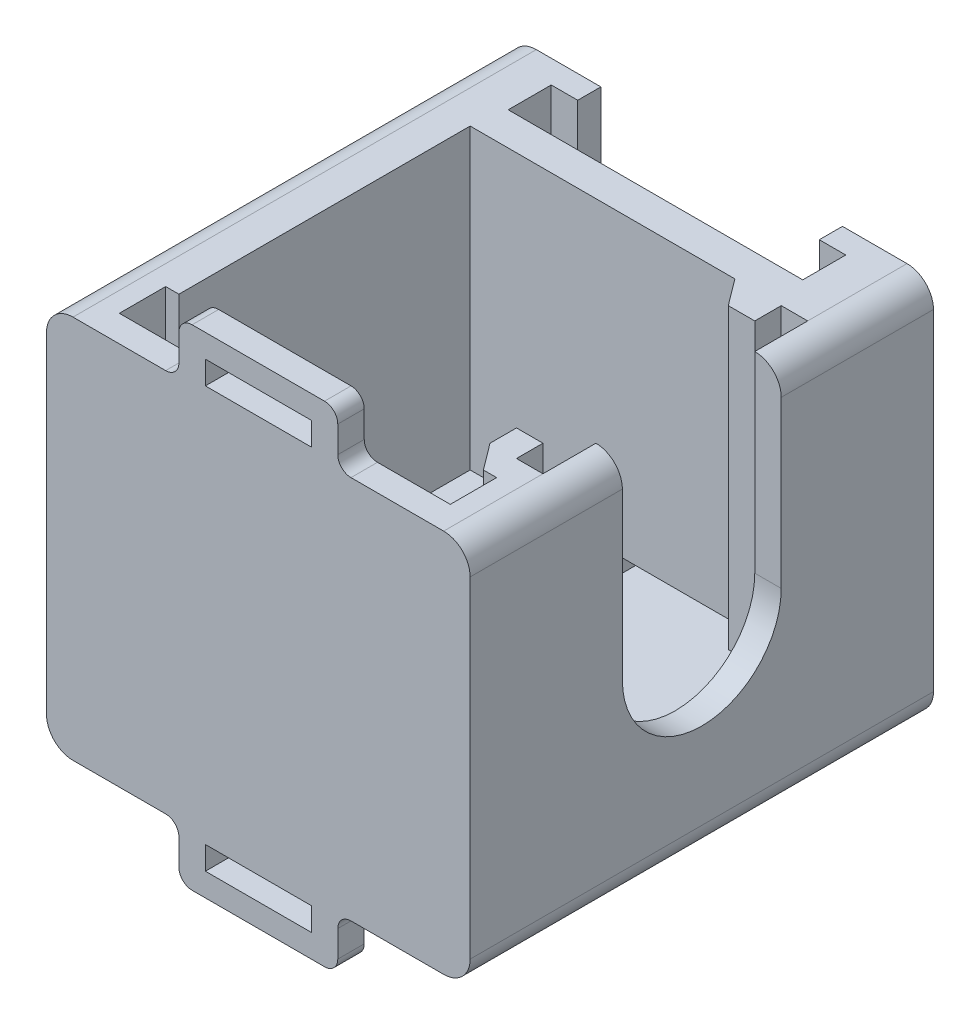
from build123d import *

# Parameters (mm, degrees)
SKETCH1_W                         = 32
SKETCH1_H                         = 29
BOSS_EXTRUDE1_DEPTH               = 35
FILLET1_R                         = 2
SLOT_FOR_COIL_DEPTH               = 1
SLOT_FOR_COIL_DEPTH_BACK          = 30
BOSS_EXTRUDE2_DEPTH               = 6.5
BOSS_EXTRUDE3_DEPTH               = 1.75
SKETCH5_W                         = 2
SKETCH5_H                         = 6.5
SLOT_TO_FEED_IN_WIRE_DEPTH        = 33
SLOT_FO_PCB_DEPTH                 = 22.5
SKETCH7_W                         = 2
SKETCH7_H                         = 33
BOSS_EXTRUDE4_DEPTH               = 2.5
FILLET2_R                         = 6
ROD_MOUNT_SLOT_REACH              = 34
SKETCH14_W                        = 2.5
SKETCH14_H                        = 20
SIDE_CAVITY_FOR_MOUNT_PLATE_DEPTH = 22.5
SKETCH16_W                        = 2
SKETCH16_H                        = 2
SIDE_STOPS_FOR_MOUNT_PLATE_DEPTH  = 22.5
BOSS_EXTRUDE6_DEPTH               = 22.5
SKETCH21_W                        = 12
SKETCH21_H                        = 2
BOSS_EXTRUDE7_DEPTH               = 4
SKETCH23_W                        = 8
SKETCH23_H                        = 1.75
CUT_EXTRUDE7_DEPTH                = 2
FILLET3_R                         = 1
CUT_EXTRUDE8_REACH                = 34
SKETCH26_R                        = 5.25


with BuildPart() as part:
    # Sketch1 → Boss-Extrude1 (new body)
    with BuildSketch(Plane.XY):
        Rectangle(SKETCH1_W, SKETCH1_H)
    extrude(amount=BOSS_EXTRUDE1_DEPTH)

    # Fillet1
    fillet1_edges = [part.edges().sort_by_distance(p)[0] for p in [
        (16, -14.5, 17.5),
        (-16, -14.5, 17.5),
        (-16, 14.5, 17.5),
        (16, 14.5, 17.5),
    ]]
    fillet(fillet1_edges, radius=FILLET1_R)

    # Sketch2 → Slot for Coil (cut, two sides)
    with BuildSketch(Plane.XZ.offset(14.5)) as slot_for_coil_sk:
        Polygon((-9.125, 0), (-9.125, 1.75), (-11.125, 1.75), (-11.125, 5), (11.125, 5), (11.125, 1.75), (9.125, 1.75), (9.125, 0), align=None)
    extrude(amount=SLOT_FOR_COIL_DEPTH, mode=Mode.SUBTRACT)
    extrude(slot_for_coil_sk.sketch, amount=-SLOT_FOR_COIL_DEPTH_BACK, mode=Mode.SUBTRACT)

    # Sketch3 → Boss-Extrude2 (add)
    with BuildSketch(Plane.XZ.offset(14.5)):
        Polygon((-9.125, 0), (-9.125, 1.75), (-11.125, 1.75), (-11.125, 5), (11.125, 5), (11.125, 1.75), (9.125, 1.75), (9.125, 0), align=None)
    extrude(amount=-BOSS_EXTRUDE2_DEPTH)

    # Sketch4 → Boss-Extrude3 (add)
    with BuildSketch(Plane(origin=(0, 0, 1.75), x_dir=(-1, 0, 0), z_dir=(0, 0, -1))):
        with BuildLine():
            Line((-9.125, 7.5), (-9.125, 6.5))
            ThreePointArc((-9.125, 6.5), (-8.875, 7), (-9.125, 7.5))
        make_face()
    boss_extrude3 = extrude(amount=BOSS_EXTRUDE3_DEPTH)

    # Mirror1: Boss-Extrude3 across plane
    add(boss_extrude3.mirror(Plane(origin=(0, 0, 0), x_dir=(0, 0, 1), z_dir=(1, 0, 0))))

    # Sketch5 → slot to feed in wire (cut)
    with BuildSketch(Plane(origin=(0, 0, 0), x_dir=(-1, 0, 0), z_dir=(0, 0, -1))):
        with Locations((0, -11.25)):
            Rectangle(SKETCH5_W, SKETCH5_H)
    extrude(amount=-SLOT_TO_FEED_IN_WIRE_DEPTH, mode=Mode.SUBTRACT)

    # Sketch6 → slot fo PCB (cut)
    with BuildSketch(Plane(origin=(0, 14.5, 0), x_dir=(1, 0, 0), z_dir=(0, 1, 0))):
        Polygon((11.5, -7.5), (-11.5, -7.5), (-11.5, -29.5), (-12.5, -29.5), (-12.5, -33), (12.5, -33), (12.5, -29.5), (11.5, -29.5), align=None)
    extrude(amount=-SLOT_FO_PCB_DEPTH, mode=Mode.SUBTRACT)

    # Sketch7 → Boss-Extrude4 (add)
    with BuildSketch(Plane.XZ.offset(14.5)):
        with Locations((0, 16.5)):
            Rectangle(SKETCH7_W, SKETCH7_H)
    extrude(amount=-BOSS_EXTRUDE4_DEPTH)

    # Fillet2
    fillet2_edges = [part.edges().sort_by_distance(p)[0] for p in [
        (0, -12, 33),
    ]]
    fillet(fillet2_edges, radius=FILLET2_R)

    # Sketch11 → Rod Mount Slot (cut, up to next)
    with BuildSketch(Plane(origin=(16, 0, 44), x_dir=(0, 0, -1), z_dir=(1, 0, 0)), mode=Mode.PRIVATE) as rod_mount_slot_sk1:
        with BuildLine():
            Line((32.5, 25), (32.5, 0))
            ThreePointArc((32.5, 0), (26.5, -6), (20.5, 0))
            Line((20.5, 0), (20.5, 25))
            ThreePointArc((20.5, 25), (26.5, 31), (32.5, 25))
        make_face()
    rod_mount_slot_tool1 = extrude(rod_mount_slot_sk1.sketch, amount=-ROD_MOUNT_SLOT_REACH, mode=Mode.PRIVATE) & part.part
    add(rod_mount_slot_tool1.solids().sort_by_distance((16, 12.5, 17.5))[0], mode=Mode.SUBTRACT)

    # Sketch14 → Side cavity for mount plate (cut)
    with BuildSketch(Plane(origin=(0, 14.5, 0), x_dir=(1, 0, 0), z_dir=(0, 1, 0))):
        with Locations((12.75, -17.5)):
            Rectangle(SKETCH14_W, SKETCH14_H)
    extrude(amount=-SIDE_CAVITY_FOR_MOUNT_PLATE_DEPTH, mode=Mode.SUBTRACT)

    # Sketch16 → Side stops for mount plate (add)
    with BuildSketch(Plane(origin=(0, 14.5, 0), x_dir=(1, 0, 0), z_dir=(0, 1, 0))):
        with Locations((11, -8.5)):
            Rectangle(SKETCH16_W, SKETCH16_H)
        with Locations((11, -26.5)):
            Rectangle(SKETCH16_W, SKETCH16_H)
    extrude(amount=-SIDE_STOPS_FOR_MOUNT_PLATE_DEPTH)

    # Sketch20 → Boss-Extrude6 (add)
    with BuildSketch(Plane(origin=(0, 14.5, 0), x_dir=(1, 0, 0), z_dir=(0, 1, 0))):
        Polygon((11.5, -29.5), (10, -27.5), (11.5, -27.5), align=None)
        Polygon((10, -9.5), (8.5, -7.5), (10, -7.5), align=None)
    extrude(amount=-BOSS_EXTRUDE6_DEPTH)

    # Sketch21 → Boss-Extrude7 (add)
    with BuildSketch(Plane(origin=(0, 14.5, 0), x_dir=(-1, 0, 0), z_dir=(0, 1, 0))):
        with Locations((0, 34)):
            Rectangle(SKETCH21_W, SKETCH21_H)
    boss_extrude7 = extrude(amount=BOSS_EXTRUDE7_DEPTH)

    # Sketch23 → Cut-Extrude7 (cut)
    with BuildSketch(Plane.XY.offset(35)):
        with Locations((0, 15.875)):
            Rectangle(SKETCH23_W, SKETCH23_H)
    cut_extrude7 = extrude(amount=-CUT_EXTRUDE7_DEPTH, mode=Mode.SUBTRACT)

    # Mirror3: Boss-Extrude7, Cut-Extrude7 across plane
    add(boss_extrude7.mirror(Plane.ZX))
    add(cut_extrude7.mirror(Plane.ZX), mode=Mode.SUBTRACT)

    # Fillet3
    fillet3_edges = [part.edges().sort_by_distance(p)[0] for p in [
        (6, 14.5, 34),
        (-6, 14.5, 34),
        (6, 18.5, 34),
        (-6, 18.5, 34),
        (6, -18.5, 34),
        (-6, -18.5, 34),
        (6, -14.5, 34),
        (-6, -14.5, 34),
    ]]
    fillet(fillet3_edges, radius=FILLET3_R)

    # Sketch26 → Cut-Extrude8 (cut, up to next)
    with BuildSketch(Plane(origin=(-16, 0, 0), x_dir=(0, 0, -1), z_dir=(1, 0, 0)), mode=Mode.PRIVATE) as cut_extrude8_sk1:
        with Locations((-23.015, -2.89)):
            Circle(SKETCH26_R)
    cut_extrude8_tool1 = extrude(cut_extrude8_sk1.sketch, amount=CUT_EXTRUDE8_REACH, mode=Mode.PRIVATE) & part.part
    add(cut_extrude8_tool1.solids().sort_by_distance((-16, -2.89, 23.015))[0], mode=Mode.SUBTRACT)


solid = part.part
